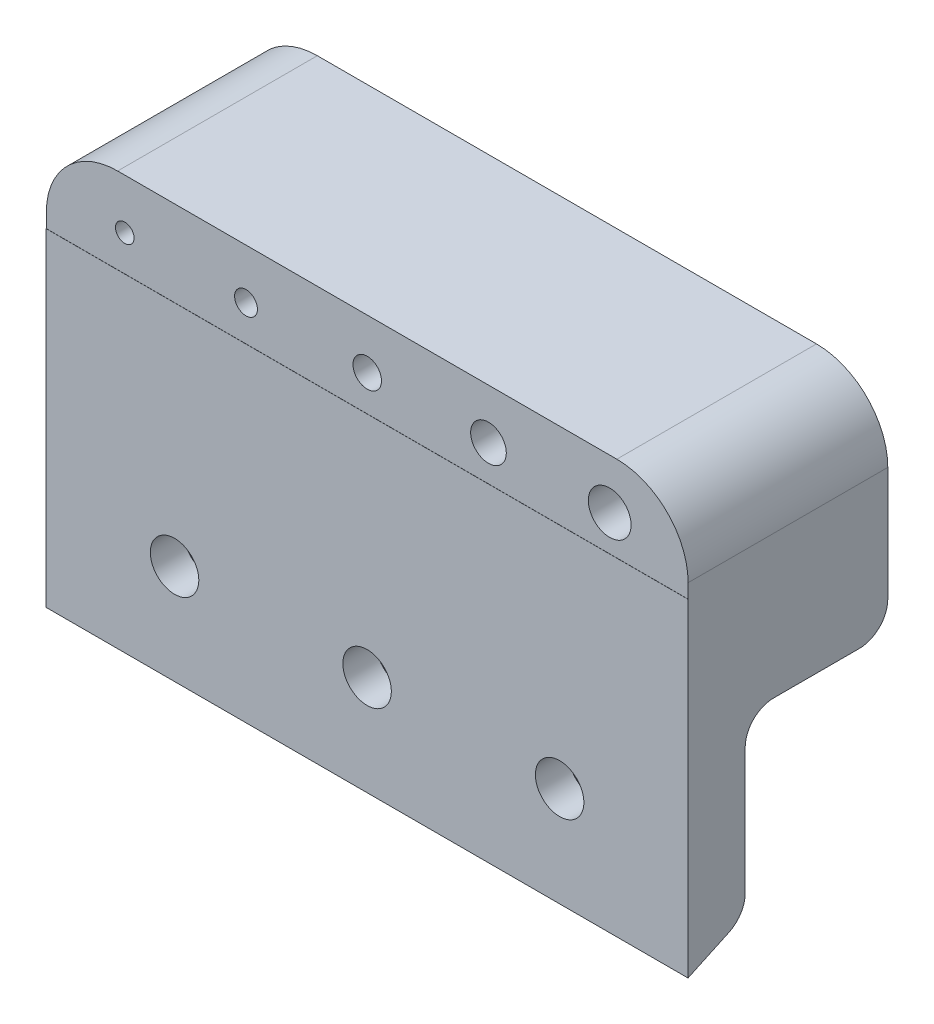
from build123d import *

# Parameters (mm, degrees)
ESQUISSE1_W                                      = 45
ESQUISSE1_H                                      = 29
BOSS_EXTRU_1_DEPTH                               = 14
ESQUISSE8_W                                      = 45
ESQUISSE8_H                                      = 23
BOSS_EXTRU_2_DEPTH                               = 0.01
ESQUISSE3_R                                      = 1
ESQUISSE3_R_2                                    = 0.8
ESQUISSE3_R_3                                    = 0.65
ESQUISSE3_R_4                                    = 1.25
ESQUISSE3_R_5                                    = 1.5
ENL_V_MAT_EXTRU_2_DEPTH                          = 1.01
ENL_V_MAT_EXTRU_2_DEPTH_BACK                     = 15
ESQUISSE4_W                                      = 10
ESQUISSE4_H                                      = 14
ENL_V_MAT_EXTRU_3_DEPTH                          = 46
CONG_1_R                                         = 5
CONG_2_R                                         = 2
ESQUISSE5_R                                      = 1.5
ENL_V_MAT_EXTRU_4_DEPTH                          = 13
FRAISAGE_POUR_VIS_T_TE_FRAIS_E_6_PAN_D           = 3.4
FRAISAGE_POUR_VIS_T_TE_FRAIS_E_6_PAN_CSINK_D     = 6.72
FRAISAGE_POUR_VIS_T_TE_FRAIS_E_6_PAN_CSINK_ANGLE = 90
TROU_POUR_TARAUDAGE_POUR_TROU_TARAUD_M5_D        = 4.2
TROU_POUR_TARAUDAGE_POUR_TROU_TARAUD_M5_DEPTH    = 6
TROU_POUR_TARAUDAGE_POUR_TROU_TARAUD_M5_TIP      = 1.2618073
D_GAGEMENT_M2_51_D                               = 2.9
D_GAGEMENT_M2_51_DEPTH                           = 5
D_GAGEMENT_M2_51_TIP                             = 0.871247898
CONG_4_R                                         = 2
CHANFREIN1_SIZE                                  = 4
CHANFREIN1_SIZE2                                 = 1.865
CONG_5_R                                         = 2


with BuildPart() as part:
    # Esquisse1 → Boss.-Extru.1 (new body)
    with BuildSketch(Plane.XY):
        Rectangle(ESQUISSE1_W, ESQUISSE1_H)
    extrude(amount=BOSS_EXTRU_1_DEPTH)

    # Esquisse8 → Boss.-Extru.2 (add)
    with BuildSketch(Plane.XY.offset(14)):
        with Locations((0, -3)):
            Rectangle(ESQUISSE8_W, ESQUISSE8_H)
    extrude(amount=BOSS_EXTRU_2_DEPTH)

    # Esquisse3 → Enlèv. mat.-Extru.2 (cut, two sides)
    with BuildSketch(Plane.XY.offset(14)) as enl_v_mat_extru_2_sk:
        with Locations((0, 11)):
            Circle(ESQUISSE3_R)
        with Locations((-8.5, 11)):
            Circle(ESQUISSE3_R_2)
        with Locations((-17, 11)):
            Circle(ESQUISSE3_R_3)
        with Locations((8.5, 11)):
            Circle(ESQUISSE3_R_4)
        with Locations((17, 11)):
            Circle(ESQUISSE3_R_5)
    extrude(amount=ENL_V_MAT_EXTRU_2_DEPTH, mode=Mode.SUBTRACT)
    extrude(enl_v_mat_extru_2_sk.sketch, amount=-ENL_V_MAT_EXTRU_2_DEPTH_BACK, mode=Mode.SUBTRACT)

    # Esquisse4 → Enlèv. mat.-Extru.3 (cut, through all)
    with BuildSketch(Plane.ZY.offset(22.5)):
        with Locations((5, -7.5)):
            Rectangle(ESQUISSE4_W, ESQUISSE4_H)
    extrude(amount=-ENL_V_MAT_EXTRU_3_DEPTH, mode=Mode.SUBTRACT)

    # Congé1
    cong_1_edges = [part.edges().sort_by_distance(p)[0] for p in [
        (22.5, 14.5, 7),
        (-22.5, 14.5, 7),
    ]]
    fillet(cong_1_edges, radius=CONG_1_R)

    # Congé2
    cong_2_edges = [part.edges().sort_by_distance(p)[0] for p in [
        (0, -0.5, 10),
    ]]
    fillet(cong_2_edges, radius=CONG_2_R)

    # Esquisse5 → Enlèv. mat.-Extru.4 (cut)
    with BuildSketch(Plane.XZ.offset(0.5)):
        with Locations(Location((17, 5, 0), (0, 0, 270))):  # turned: the seam where the file's is
            Circle(ESQUISSE5_R)
        with Locations(Location((8.5, 5, 0), (0, 0, 270))):  # turned: the seam where the file's is
            Circle(ESQUISSE5_R)
        with Locations(Location((0, 5, 0), (0, 0, 270))):  # turned: the seam where the file's is
            Circle(ESQUISSE5_R)
        with Locations(Location((-8.5, 5, 0), (0, 0, 270))):  # turned: the seam where the file's is
            Circle(ESQUISSE5_R)
        with Locations(Location((-17, 5, 0), (0, 0, 270))):  # turned: the seam where the file's is
            Circle(ESQUISSE5_R)
    extrude(amount=-ENL_V_MAT_EXTRU_4_DEPTH, mode=Mode.SUBTRACT)

    # Fraisage pour vis à tête fraisée à 6 pans creux M31 (through all)
    with Locations(Plane(origin=(0, 0, 10), x_dir=(-1, 0, 0), z_dir=(0, 0, -1))):
        with Locations((-13.5, -7.5), (13.5, -7.5), (0, -7.5)):
            CounterSinkHole(FRAISAGE_POUR_VIS_T_TE_FRAIS_E_6_PAN_D / 2, FRAISAGE_POUR_VIS_T_TE_FRAIS_E_6_PAN_CSINK_D / 2, counter_sink_angle=FRAISAGE_POUR_VIS_T_TE_FRAIS_E_6_PAN_CSINK_ANGLE)

    # Trou pour taraudage pour trou taraudé M51
    with Locations(Plane(origin=(0, -0.5, 0), x_dir=(-1, 0, 0), z_dir=(0, -1, 0))):
        with Locations((17, -5), (8.5, -5), (0, -5), (-8.5, -5), (-17, -5)):
            Hole(TROU_POUR_TARAUDAGE_POUR_TROU_TARAUD_M5_D / 2, depth=TROU_POUR_TARAUDAGE_POUR_TROU_TARAUD_M5_DEPTH)
            with Locations((0, 0, -(TROU_POUR_TARAUDAGE_POUR_TROU_TARAUD_M5_DEPTH + TROU_POUR_TARAUDAGE_POUR_TROU_TARAUD_M5_TIP / 2))):  # 118° drill point
                Cone(0, TROU_POUR_TARAUDAGE_POUR_TROU_TARAUD_M5_D / 2, TROU_POUR_TARAUDAGE_POUR_TROU_TARAUD_M5_TIP, mode=Mode.SUBTRACT)

    # Dégagement M2.51
    with Locations(Plane(origin=(0, 0, 0), x_dir=(-1, 0, 0), z_dir=(0, 0, -1))):
        with Locations((-12.5, 8.5), (12.5, 8.5)):
            Hole(D_GAGEMENT_M2_51_D / 2, depth=D_GAGEMENT_M2_51_DEPTH)
            with Locations((0, 0, -(D_GAGEMENT_M2_51_DEPTH + D_GAGEMENT_M2_51_TIP / 2))):  # 118° drill point
                Cone(0, D_GAGEMENT_M2_51_D / 2, D_GAGEMENT_M2_51_TIP, mode=Mode.SUBTRACT)

    # Congé4
    cong_4_edges = [part.edges().sort_by_distance(p)[0] for p in [
        (0, -0.5, 0),
    ]]
    fillet(cong_4_edges, radius=CONG_4_R)

    # Chanfrein1
    chanfrein1_edges = [part.edges().sort_by_distance(p)[0] for p in [
        (0, -14.5, 10),
    ]]
    chanfrein1_side = [part.faces().sort_by_distance(p)[0] for p in [
        (0, -14.5, 12.005),
    ]]
    chamfer(chanfrein1_edges, length=CHANFREIN1_SIZE, length2=CHANFREIN1_SIZE2, reference=chanfrein1_side[0])

    # Congé5
    cong_5_edges = [part.edges().sort_by_distance(p)[0] for p in [
        (0, -12.635, 10),
    ]]
    fillet(cong_5_edges, radius=CONG_5_R)


solid = part.part
